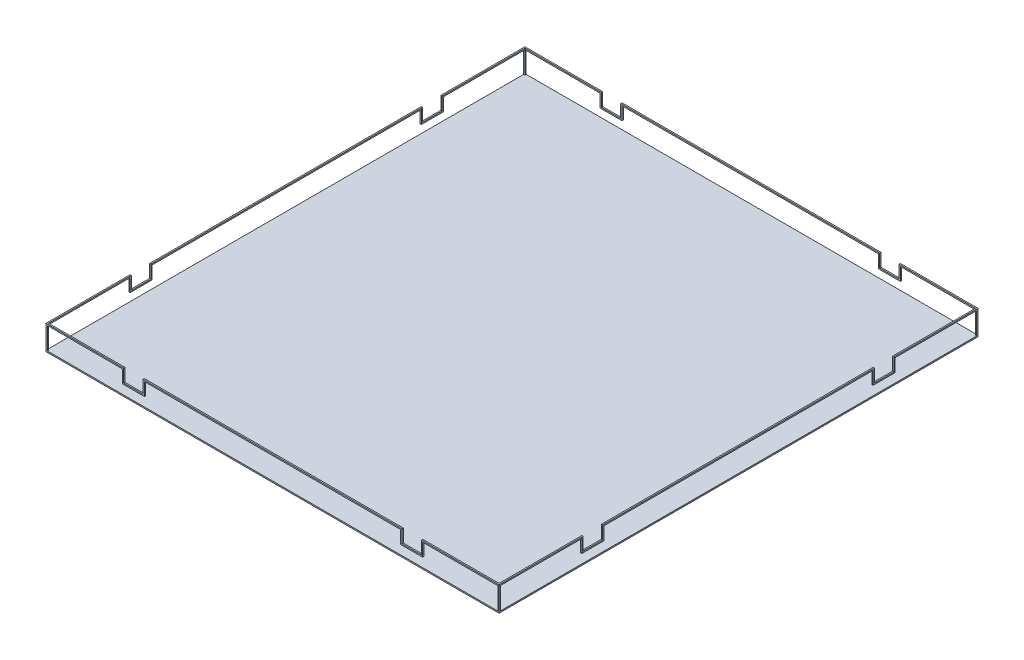
from build123d import *

# Parameters (mm, degrees)
SKETCH_1_W             = 35
SKETCH_1_H             = 37
EXTRUDE_1_DEPTH        = 0.1
EXTRUDE_2_DEPTH        = 0.1
EXTRUDE_3_DEPTH        = 0.1
PATTERN_LINEAR_1_COUNT = 2
PATTERN_LINEAR_1_PITCH = 36.9
PATTERN_LINEAR_2_COUNT = 2
PATTERN_LINEAR_2_PITCH = 34.9


with BuildPart() as part:
    # 草图1 → 凸台-拉伸1 (new body)
    with BuildSketch(Plane(origin=(0, 0, 0), x_dir=(1, 0, 0), z_dir=(0, 1, 0))):
        with Locations((17.5, 18.5)):
            Rectangle(SKETCH_1_W, SKETCH_1_H)
    extrude(amount=-EXTRUDE_1_DEPTH)

    # 草图2 → 拉伸-薄壁2 (add)
    with BuildSketch(Plane.XY):
        Polygon((0, 0), (0, 1.8), (6, 1.8), (6, 0.8), (7.5, 0.8), (7.5, 1.8), (27.5, 1.8), (27.5, 0.8), (29, 0.8), (29, 1.8), (35, 1.8), (35, 0), (34.9, 0), (34.9, 1.7), (29.1, 1.7), (29.1, 0.7), (27.4, 0.7), (27.4, 1.7), (7.6, 1.7), (7.6, 0.7), (5.9, 0.7), (5.9, 1.7), (0.1, 1.7), (0.1, 0), align=None)
    extrude_2 = extrude(amount=-EXTRUDE_2_DEPTH)

    # 草图3 → 拉伸-薄壁3 (add)
    with BuildSketch(Plane(origin=(0, 0, 0), x_dir=(0, 0, -1), z_dir=(1, 0, 0))):
        Polygon((0, 1.8), (6.5, 1.8), (6.5, 0.8), (8, 0.8), (8, 1.8), (29, 1.8), (29, 0.8), (30.5, 0.8), (30.5, 1.8), (37, 1.8), (37, 0), (36.9, 0), (36.9, 1.7), (30.6, 1.7), (30.6, 0.7), (28.9, 0.7), (28.9, 1.7), (8.1, 1.7), (8.1, 0.7), (6.4, 0.7), (6.4, 1.7), (0, 1.7), align=None)
    extrude_3 = extrude(amount=EXTRUDE_3_DEPTH)

    # 阵列(线性)1: 拉伸-薄壁2 ×2
    with Locations(*[(0, 0, -i * PATTERN_LINEAR_1_PITCH) for i in range(1, PATTERN_LINEAR_1_COUNT)]):
        add(extrude_2)

    # 阵列(线性)2: 拉伸-薄壁3 ×2
    with Locations(*[(i * PATTERN_LINEAR_2_PITCH, 0, 0) for i in range(1, PATTERN_LINEAR_2_COUNT)]):
        add(extrude_3)


solid = part.part
